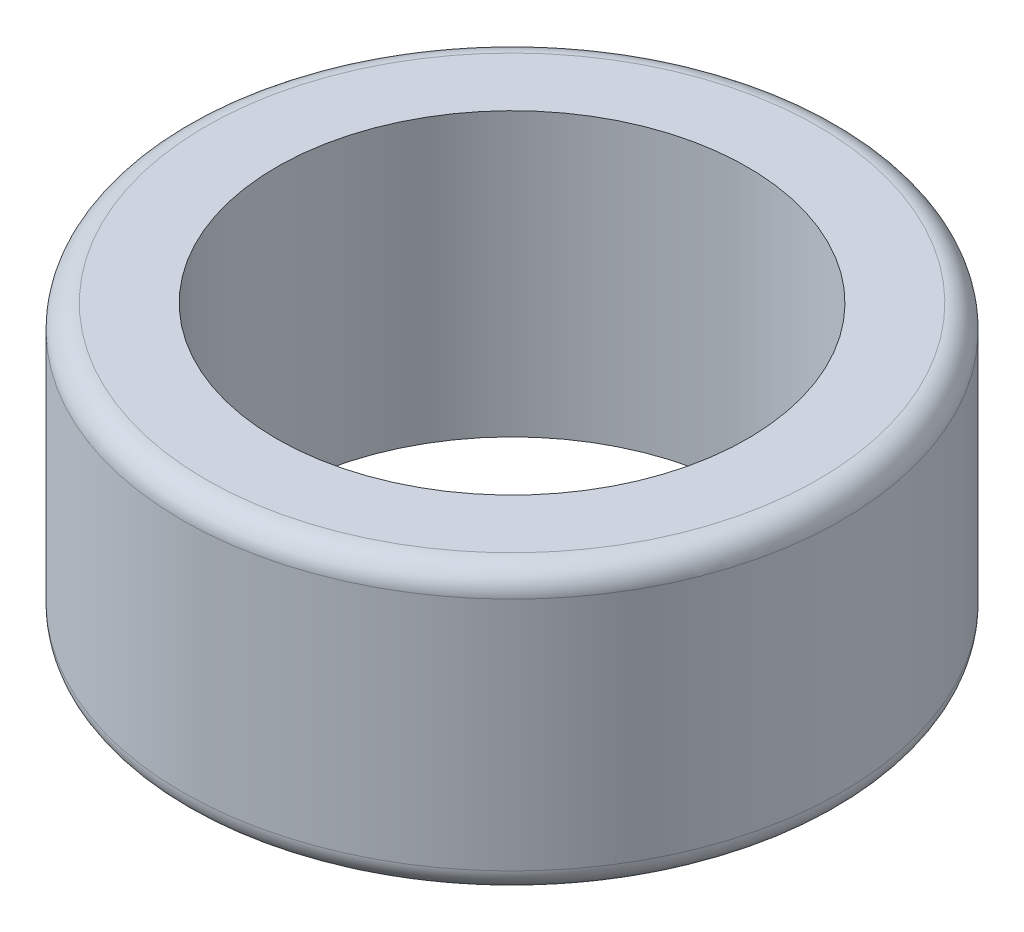
from build123d import *

# Parameters (mm, degrees)
SKETCH1_R           = 7
SKETCH1_R_2         = 5
BOSS_EXTRUDE1_DEPTH = 6
FILLET1_R           = 0.5


with BuildPart() as part:
    # Sketch1 → Boss-Extrude1 (new body)
    with BuildSketch(Plane(origin=(0, 0, 0), x_dir=(1, 0, 0), z_dir=(0, 1, 0))):
        Circle(SKETCH1_R)
        Circle(SKETCH1_R_2, mode=Mode.SUBTRACT)
    extrude(amount=BOSS_EXTRUDE1_DEPTH)

    # Fillet1
    fillet1_edges = [part.edges().sort_by_distance(p)[0] for p in [
        (-7, 0, 0),
        (-7, 6, 0),
    ]]
    fillet(fillet1_edges, radius=FILLET1_R)


solid = part.part
